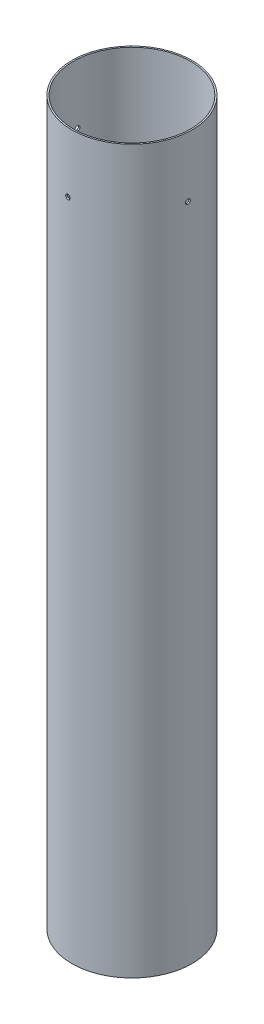
from build123d import *

# Parameters (mm, degrees)
SKETCH1_R           = 50.8
SKETCH1_R_2         = 49.53
BOSS_EXTRUDE1_DEPTH = 609.6
SKETCH2_R           = 1.984375
CUT_EXTRUDE1_DEPTH  = 12.7
CIRPATTERN1_COUNT   = 4


with BuildPart() as part:
    # Sketch1 → Boss-Extrude1 (new body)
    with BuildSketch(Plane(origin=(0, 0, 0), x_dir=(1, 0, 0), z_dir=(0, 1, 0))):
        Circle(SKETCH1_R)
        Circle(SKETCH1_R_2, mode=Mode.SUBTRACT)
    extrude(amount=BOSS_EXTRUDE1_DEPTH)

    # Sketch2 → Cut-Extrude1 (cut)
    with BuildSketch(Plane(origin=(122.899951256, 815.595371644, -42.551362721), x_dir=(-0.997691035, 0, -0.067916112), z_dir=(0.067916112, 0, -0.997691035))):
        with Locations((119.72625647, -256.795371644)):
            Circle(SKETCH2_R)
    cut_extrude1 = extrude(amount=-CUT_EXTRUDE1_DEPTH, mode=Mode.SUBTRACT)

    # CirPattern1: Cut-Extrude1 ×4 about axis
    cirpattern1_axis = Axis((0, 0, 0), (0, -1, 0))
    for i in range(1, CIRPATTERN1_COUNT):
        add(cut_extrude1.rotate(cirpattern1_axis, i * 360 / CIRPATTERN1_COUNT), mode=Mode.SUBTRACT)


solid = part.part
